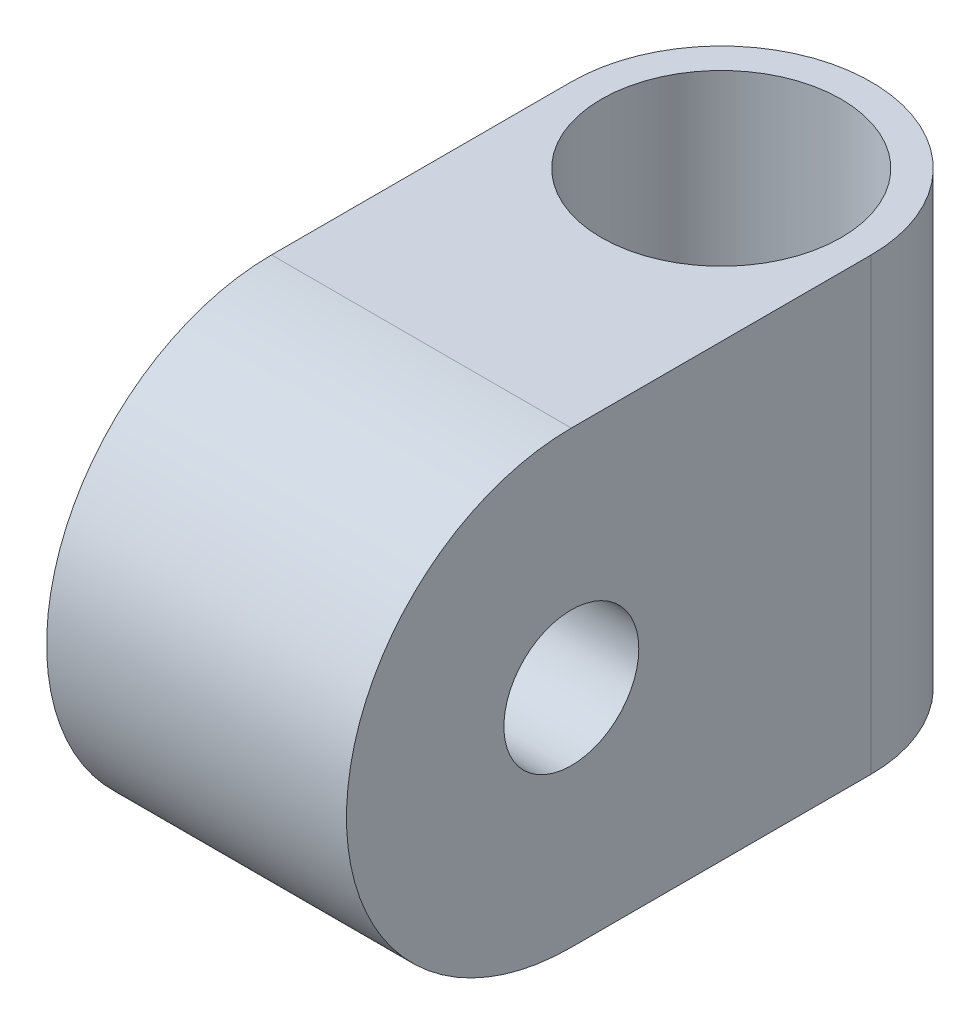
from build123d import *

# Parameters (mm, degrees)
SKETCH1_R               = 2.25
BOSS_EXTRUDE1_DEPTH     = 5
SKETCH2_R               = 4
CUT_EXTRUDE1_DEPTH      = 1
CUT_EXTRUDE1_DEPTH_BACK = 16


with BuildPart() as part:
    # Sketch1 → Boss-Extrude1 (new body, symmetric)
    with BuildSketch(Plane(origin=(0, 0, 0), x_dir=(0, 0, -1), z_dir=(1, 0, 0))):
        with BuildLine():
            Line((7.5, -7.5), (-7.5, -7.5))
            ThreePointArc((-7.5, -7.5), (-15, 0), (-7.5, 7.5))
            Line((-7.5, 7.5), (7.5, 7.5))
            Line((7.5, 7.5), (7.5, -7.5))
        make_face()
        with Locations((-7.5, 0)):
            Circle(SKETCH1_R, mode=Mode.SUBTRACT)
    extrude(amount=BOSS_EXTRUDE1_DEPTH, both=True)

    # Sketch2 → Cut-Extrude1 (cut, two sides)
    with BuildSketch(Plane(origin=(0, 7.5, 0), x_dir=(1, 0, 0), z_dir=(0, 1, 0))) as cut_extrude1_sk:
        Polygon((-5, 10.919306059), (-5, 7.5), (0, 7.5), (5, 7.5), (5, 10.919306059), align=None)
        with BuildLine():
            Line((-5, 7.5), (-5, 2.5))
            ThreePointArc((-5, 2.5), (-3.535533906, 6.035533906), (0, 7.5))
            Line((0, 7.5), (-5, 7.5))
        make_face()
        with BuildLine():
            ThreePointArc((0, 7.5), (3.535533906, 6.035533906), (5, 2.5))
            Line((5, 2.5), (5, 7.5))
            Line((5, 7.5), (0, 7.5))
        make_face()
        with Locations((0, 2.5)):
            Circle(SKETCH2_R)
    extrude(amount=CUT_EXTRUDE1_DEPTH, mode=Mode.SUBTRACT)
    extrude(cut_extrude1_sk.sketch, amount=-CUT_EXTRUDE1_DEPTH_BACK, mode=Mode.SUBTRACT)


solid = part.part
